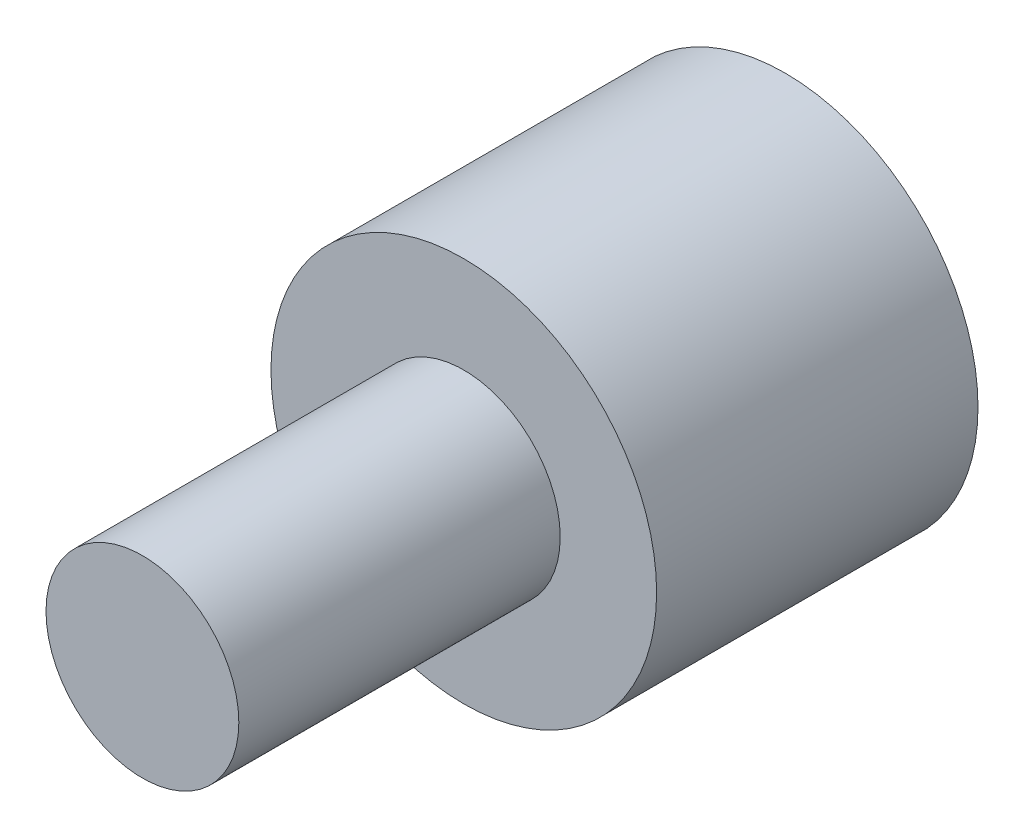
from build123d import *

# Parameters (mm, degrees)
SKETCH_1_R          = 12
EXTRUDE_2_DEPTH     = 20
SKETCH_2_R          = 6
EXTRUDE_3_DEPTH     = 20
SKETCH_3_R          = 5
CUT_EXTRUDE_1_DEPTH = 12


with BuildPart() as part:
    # 草圖1 → 填料-伸長2 (new body)
    with BuildSketch(Plane.XY):
        Circle(SKETCH_1_R)
    extrude(amount=EXTRUDE_2_DEPTH)

    # 草圖2 → 填料-伸長3 (add)
    with BuildSketch(Plane.XY.offset(20)):
        Circle(SKETCH_2_R)
    extrude(amount=EXTRUDE_3_DEPTH)

    # 草圖3 → 除料-伸長1 (cut)
    with BuildSketch(Plane(origin=(0, 0, 0), x_dir=(-1, 0, 0), z_dir=(0, 0, -1))):
        Circle(SKETCH_3_R)
    extrude(amount=-CUT_EXTRUDE_1_DEPTH, mode=Mode.SUBTRACT)


solid = part.part
